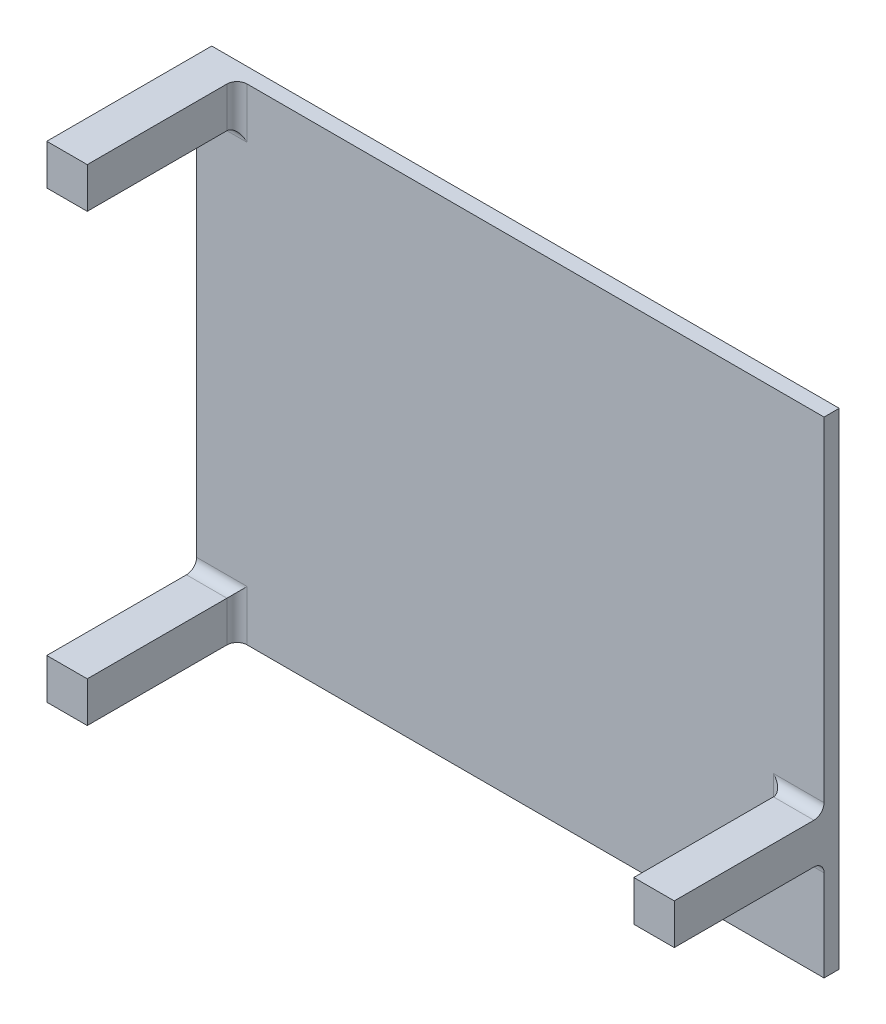
from build123d import *

# Parameters (mm, degrees)
SKIZZE1_W                       = 62
SKIZZE1_H                       = 48
AUFSATZ_LINEAR_AUSTRAGEN1_DEPTH = 1.5
SKIZZE3_W                       = 4
SKIZZE3_H                       = 4
AUFSATZ_LINEAR_AUSTRAGEN2_DEPTH = 14.8
VERRUNDUNG1_R                   = 1


with BuildPart() as part:
    # Skizze1 → Aufsatz-Linear austragen1 (new body)
    with BuildSketch(Plane.XY):
        with Locations((-8.433613499, 5.076642336)):
            Rectangle(SKIZZE1_W, SKIZZE1_H)
    extrude(amount=AUFSATZ_LINEAR_AUSTRAGEN1_DEPTH)

    # Skizze3 → Aufsatz-Linear austragen2 (add)
    with BuildSketch(Plane.XY.offset(1.5)):
        with Locations((-37.433613499, 27.076642336)):
            Rectangle(SKIZZE3_W, SKIZZE3_H)
        with Locations((-37.433613499, -16.923357664)):
            Rectangle(SKIZZE3_W, SKIZZE3_H)
        with Locations((20.566386501, -6.923357664)):
            Rectangle(SKIZZE3_W, SKIZZE3_H)
    extrude(amount=AUFSATZ_LINEAR_AUSTRAGEN2_DEPTH)

    # Verrundung1
    verrundung1_edges = [part.edges().sort_by_distance(p)[0] for p in [
        (-37.433613499, 25.076642336, 1.5),
        (-35.433613499, 27.076642336, 1.5),
        (-35.433613499, -16.923357664, 1.5),
        (-37.433613499, -14.923357664, 1.5),
        (20.566386501, -4.923357664, 1.5),
        (18.566386501, -6.923357664, 1.5),
        (20.566386501, -8.923357664, 1.5),
    ]]
    fillet(verrundung1_edges, radius=VERRUNDUNG1_R)


solid = part.part
